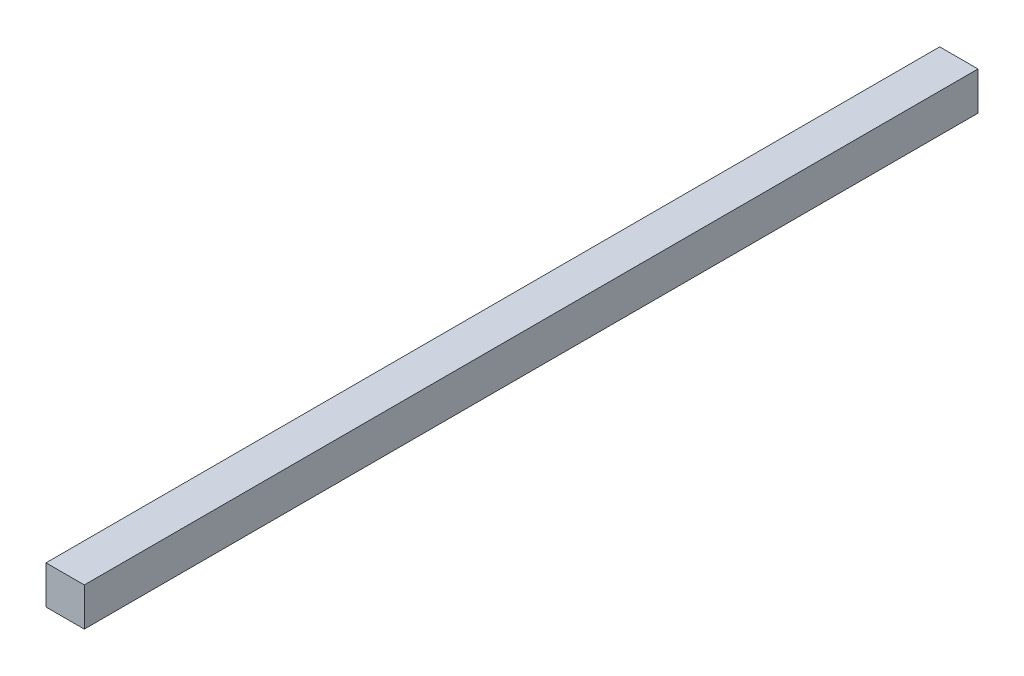
from build123d import *

# Parameters (mm, degrees)
SKETCH1_W           = 15
SKETCH1_H           = 15
BOSS_EXTRUDE1_DEPTH = 350


with BuildPart() as part:
    # Sketch1 → Boss-Extrude1 (new body)
    with BuildSketch(Plane.XY):
        Rectangle(SKETCH1_W, SKETCH1_H)
    extrude(amount=BOSS_EXTRUDE1_DEPTH)


solid = part.part
